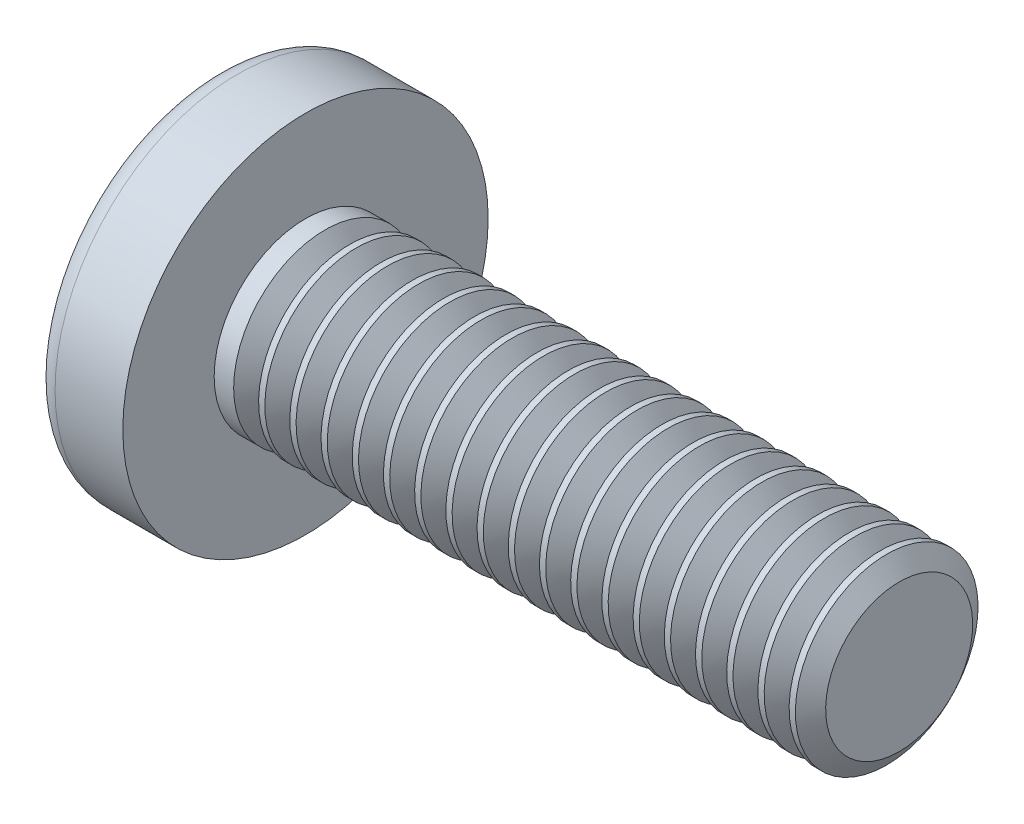
from build123d import *

# Parameters (mm, degrees)
SKETCH3_W         = 0.93
SKETCH3_H         = 4.4
SKETCH4_W         = 0.465
SKETCH4_H         = 0.465
CIRPATTERN1_COUNT = 2
CIRPATTERN1_ANGLE = 90
THDSCHPAT_COUNT   = 19
THDSCHPAT_PITCH   = 0.683333333
ESCALA1_SCALE     = 7


with BuildPart() as part:
    # BodySke → Base-Revolve (revolve)
    with BuildSketch(Plane.XY):
        with BuildLine():
            Line((3.1, 2), (3.1, 4))
            Line((3.1, 4), (1.616353821, 4))
            ThreePointArc((1.616353821, 4), (1.397629036, 3.947269784), (1.226960106, 3.800664452))
            ThreePointArc((1.226960106, 3.800664452), (0.314340807, 1.996902688), (0, 0))
            Line((0, 0), (16.1, 0))
            Line((16.1, 0), (16.1, 2))
            Line((16.1, 2), (3.1, 2))
        make_face()
    revolve(axis=Axis((-25.4, 0, 0), (1, 0, 0)))

    # Sketch3 → Cut-Loft1 section 0
    with BuildSketch(Plane(origin=(0, 0, 0), x_dir=(0, 0, -1), z_dir=(1, 0, 0))):
        Rectangle(SKETCH3_W, SKETCH3_H)
    # Sketch4 → Cut-Loft1 section 1
    with BuildSketch(Plane(origin=(2.45, 0, 0), x_dir=(0, 0, -1), z_dir=(1, 0, 0))):
        Rectangle(SKETCH4_W, SKETCH4_H)
    cut_loft1 = loft(mode=Mode.SUBTRACT)

    # CirPattern1: Cut-Loft1 ×2 about axis
    cirpattern1_axis = Axis((0, 0, 0), (1, 0, 0))
    for i in range(1, CIRPATTERN1_COUNT):
        add(cut_loft1.rotate(cirpattern1_axis, i * CIRPATTERN1_ANGLE / (CIRPATTERN1_COUNT - 1)), mode=Mode.SUBTRACT)

    # ThdSchSke → ThreadSchematic (revolve, cut)
    with BuildSketch(Plane.XY):
        Polygon((3.8, -1.61), (3.52691906, -2), (3.52691906, -2.5), (4.07308094, -2.5), (4.07308094, -2), align=None)
    threadschematic = revolve(axis=Axis((-3.175, 0, 0), (1, 0, 0)), mode=Mode.SUBTRACT)

    # ThdSchPat: ThreadSchematic ×19
    with Locations(*[(i * THDSCHPAT_PITCH, 0, 0) for i in range(1, THDSCHPAT_COUNT)]):
        add(threadschematic, mode=Mode.SUBTRACT)


with BuildPart() as part_1:
    # Escala1: scaled about (6.110833127, 6e-09, -3.9e-08)
    add(part.part.scale(ESCALA1_SCALE).moved(Location((-36.664998762, -3.6e-08, 2.34e-07))))


solid = part_1.part
